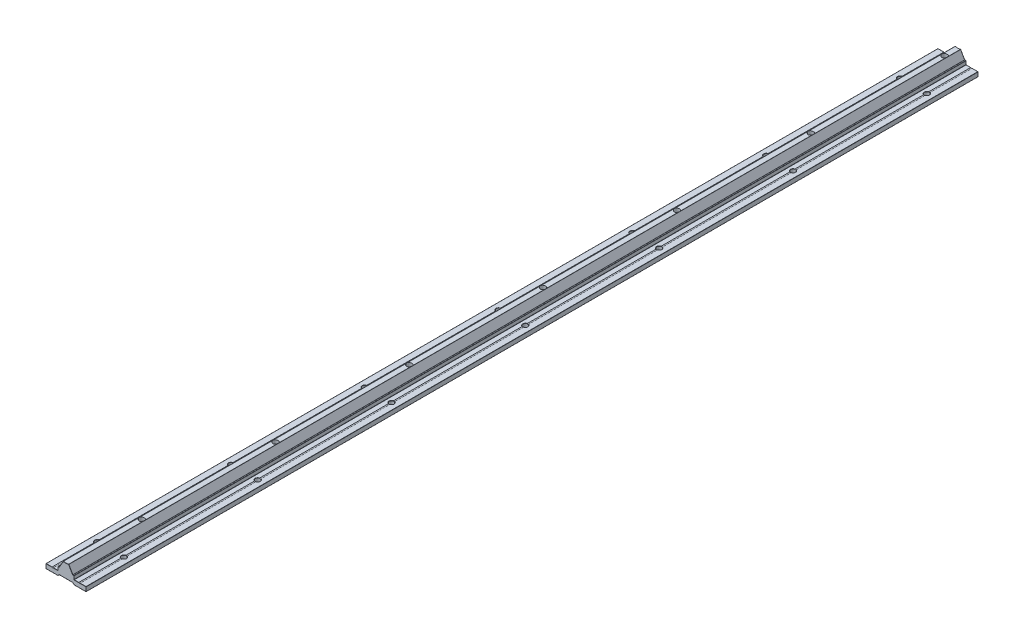
from build123d import *

# Parameters (mm, degrees)
BOSS_EXTRUDE1_DEPTH        = 1000
FILLET1_R                  = 0.2
SKETCH2_R                  = 2.75
CUT_EXTRUDE1_DEPTH         = 5
CHAMFER1_SIZE              = 0.2
LPATTERN1_COUNT            = 7
LPATTERN1_PITCH            = 150
CHAMFER1_OF_LPATTERN1_SIZE = 0.2
SKETCH3_R                  = 3
CUT_EXTRUDE2_DEPTH         = 16.462216412
SKETCH4_R                  = 5
CUT_EXTRUDE3_DEPTH         = 6
LPATTERN2_COUNT            = 7
LPATTERN2_PITCH            = 150
SKETCH5_R                  = 0.8
CUT_EXTRUDE6_DEPTH         = 1001.0000001


with BuildPart() as part:
    # Sketch1 → Boss-Extrude1 (new body)
    with BuildSketch(Plane.XY):
        with BuildLine():
            Line((-3, 0), (-7.618802154, -8))
            Line((-7.618802154, -8), (-9, -8))
            Line((-9, -8), (-9, -12))
            Line((-9, -12), (-22.5, -12))
            Line((-22.5, -12), (-22.5, -17))
            Line((-22.5, -17), (-9, -17))
            Line((-9, -17), (-7.618802154, -15.5))
            Line((-7.618802154, -15.5), (7.618802154, -15.5))
            Line((7.618802154, -15.5), (9, -17))
            Line((9, -17), (22.5, -17))
            Line((22.5, -17), (22.5, -12))
            Line((22.5, -12), (9, -12))
            Line((9, -12), (9, -8))
            Line((9, -8), (7.618802154, -8))
            Line((7.618802154, -8), (3, 0))
            ThreePointArc((3, 0), (0, -0.460607986), (-3, 0))
        make_face()
    extrude(amount=BOSS_EXTRUDE1_DEPTH)

    # Fillet1
    fillet1_edges = [part.edges().sort_by_distance(p)[0] for p in [
        (0, -15.5, 1000),
        (8.309401077, -16.25, 1000),
        (-22.5, -14.5, 0),
        (-15.75, -12, 0),
        (-9, -10, 0),
        (-8.309401077, -8, 0),
        (-5.309401077, -4, 0),
        (15.75, -17, 1000),
        (0, -0.460607986, 0),
        (5.309401077, -4, 0),
        (8.309401077, -8, 0),
        (9, -10, 0),
        (15.75, -12, 0),
        (22.5, -14.5, 0),
        (15.75, -17, 0),
        (8.309401077, -16.25, 0),
        (22.5, -14.5, 1000),
        (0, -15.5, 0),
        (-8.309401077, -16.25, 0),
        (-15.75, -17, 0),
        (15.75, -12, 1000),
        (9, -10, 1000),
        (-22.5, -17, 500),
        (-22.5, -12, 500),
        (-9, -12, 500),
        (-9, -8, 500),
        (-7.618802154, -8, 500),
        (-3, 0, 500),
        (3, 0, 500),
        (7.618802154, -8, 500),
        (9, -8, 500),
        (9, -12, 500),
        (22.5, -12, 500),
        (22.5, -17, 500),
        (9, -17, 500),
        (7.618802154, -15.5, 500),
        (-7.618802154, -15.5, 500),
        (-9, -17, 500),
        (8.309401077, -8, 1000),
        (5.309401077, -4, 1000),
        (0, -0.460607986, 1000),
        (-5.309401077, -4, 1000),
        (-15.75, -17, 1000),
        (-8.309401077, -8, 1000),
        (-9, -10, 1000),
        (-15.75, -12, 1000),
        (-22.5, -14.5, 1000),
        (-8.309401077, -16.25, 1000),
    ]]
    fillet(fillet1_edges, radius=FILLET1_R)

    # Sketch2 → Cut-Extrude1 (cut)
    with BuildSketch(Plane.XZ.offset(17)):
        with Locations((-15, 50)):
            Circle(SKETCH2_R)
        with Locations((15, 50)):
            Circle(SKETCH2_R)
    cut_extrude1 = extrude(amount=-CUT_EXTRUDE1_DEPTH, mode=Mode.SUBTRACT)

    # Chamfer1
    chamfer1_edges = [part.edges().sort_by_distance(p)[0] for p in [
        (-17.75, -17, 50),
        (-17.75, -12, 50),
        (12.25, -17, 50),
        (12.25, -12, 50),
    ]]
    chamfer(chamfer1_edges, length=CHAMFER1_SIZE)

    # LPattern1: Cut-Extrude1 ×7
    with Locations(*[(0, 0, i * LPATTERN1_PITCH) for i in range(1, LPATTERN1_COUNT)]):
        add(cut_extrude1, mode=Mode.SUBTRACT)

    # Chamfer1 of LPattern1
    chamfer1_of_lpattern1_edges = [part.edges().sort_by_distance(p)[0] for p in [
        (-17.75, -17, 200),
        (-17.75, -12, 200),
        (12.25, -17, 200),
        (12.25, -12, 200),
        (-17.75, -17, 350),
        (-17.75, -12, 350),
        (12.25, -17, 350),
        (12.25, -12, 350),
        (-17.75, -17, 500),
        (-17.75, -12, 500),
        (12.25, -17, 500),
        (12.25, -12, 500),
        (-17.75, -17, 650),
        (-17.75, -12, 650),
        (12.25, -17, 650),
        (12.25, -12, 650),
        (-17.75, -17, 800),
        (-17.75, -12, 800),
        (12.25, -17, 800),
        (12.25, -12, 800),
        (-17.75, -17, 950),
        (-17.75, -12, 950),
        (12.25, -17, 950),
        (12.25, -12, 950),
    ]]
    chamfer(chamfer1_of_lpattern1_edges, length=CHAMFER1_OF_LPATTERN1_SIZE)

    # Sketch3 → Cut-Extrude2 (cut, through all)
    with BuildSketch(Plane.XZ.offset(15.5)):
        with Locations((0, 15)):
            Circle(SKETCH3_R)
    cut_extrude2 = extrude(amount=-CUT_EXTRUDE2_DEPTH, mode=Mode.SUBTRACT)

    # Sketch4 → Cut-Extrude3 (cut)
    with BuildSketch(Plane.XZ.offset(15.5)):
        with Locations((0, 15)):
            Circle(SKETCH4_R)
    cut_extrude3 = extrude(amount=-CUT_EXTRUDE3_DEPTH, mode=Mode.SUBTRACT)

    # LPattern2: Cut-Extrude2, Cut-Extrude3 ×7
    with Locations(*[(0, 0, i * LPATTERN2_PITCH) for i in range(1, LPATTERN2_COUNT)]):
        add(cut_extrude2, mode=Mode.SUBTRACT)
        add(cut_extrude3, mode=Mode.SUBTRACT)

    # Sketch5 → Cut-Extrude6 (cut, through all)
    with BuildSketch(Plane.XY):
        with Locations((-15, -11.6)):
            Circle(SKETCH5_R)
        with Locations((15, -11.6)):
            Circle(SKETCH5_R)
    extrude(amount=CUT_EXTRUDE6_DEPTH, mode=Mode.SUBTRACT)


solid = part.part
